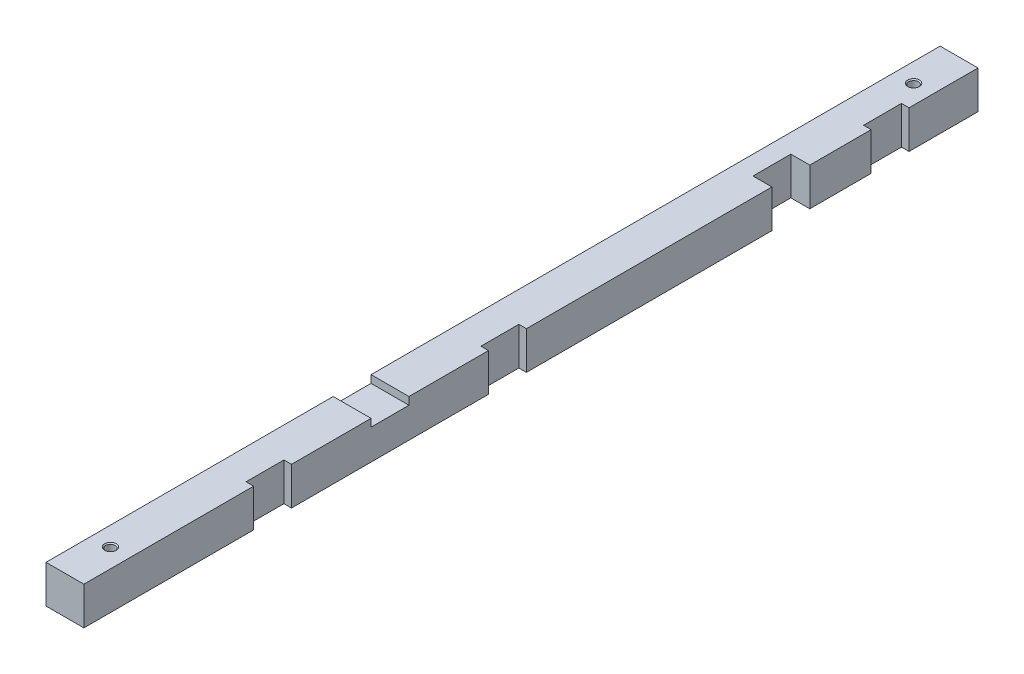
from build123d import *

# Parameters (mm, degrees)
ESQUISSE1_W                     = 10
ESQUISSE1_H                     = 10
BOSS_EXTRU_1_DEPTH              = 234
BOSS_EXTRU_1_DEPTH_BACK         = 2
ESQUISSE2_W                     = 2
ESQUISSE2_H                     = 10
ESQUISSE2_W_2                   = 5
ENL_V_MAT_EXTRU_1_DEPTH         = 11
ESQUISSE3_W                     = 10
ESQUISSE3_H                     = 2
ENL_V_MAT_EXTRU_2_DEPTH         = 11
TROU_TARAUD_M3X0_51_D           = 2.5
TROU_TARAUD_M3X0_51_CSINK_D     = 3.05
TROU_TARAUD_M3X0_51_CSINK_ANGLE = 90


with BuildPart() as part:
    # Esquisse1 → Boss.-Extru.1 (new body, two sides)
    with BuildSketch(Plane.XY) as boss_extru_1_sk:
        Rectangle(ESQUISSE1_W, ESQUISSE1_H)
    extrude(amount=BOSS_EXTRU_1_DEPTH)
    extrude(boss_extru_1_sk.sketch, amount=-BOSS_EXTRU_1_DEPTH_BACK)

    # Esquisse2 → Enl_v. mat.-Extru.1 (cut, through all)
    with BuildSketch(Plane(origin=(0, 5, 0), x_dir=(1, 0, 0), z_dir=(0, 1, 0))):
        with Locations((4, -122.2)):
            Rectangle(ESQUISSE2_W, ESQUISSE2_H)
        with Locations((4, -184.2)):
            Rectangle(ESQUISSE2_W, ESQUISSE2_H)
        with Locations((4, -21.2)):
            Rectangle(ESQUISSE2_W, ESQUISSE2_H)
        with Locations((2.5, -47.4)):
            Rectangle(ESQUISSE2_W_2, ESQUISSE2_H)
    extrude(amount=-ENL_V_MAT_EXTRU_1_DEPTH, mode=Mode.SUBTRACT)

    # Esquisse3 → Enl_v. mat.-Extru.2 (cut, through all)
    with BuildSketch(Plane.ZY.offset(5)):
        with Locations((153.2, 4)):
            Rectangle(ESQUISSE3_W, ESQUISSE3_H)
    extrude(amount=-ENL_V_MAT_EXTRU_2_DEPTH, mode=Mode.SUBTRACT)

    # Trou taraud_ M3x0.51 (through all)
    with Locations(Plane(origin=(0, 5, 0), x_dir=(1, 0, 0), z_dir=(0, 1, 0))):
        with Locations((0, -222), (0, -10)):
            CounterSinkHole(TROU_TARAUD_M3X0_51_D / 2, TROU_TARAUD_M3X0_51_CSINK_D / 2, counter_sink_angle=TROU_TARAUD_M3X0_51_CSINK_ANGLE)


solid = part.part
